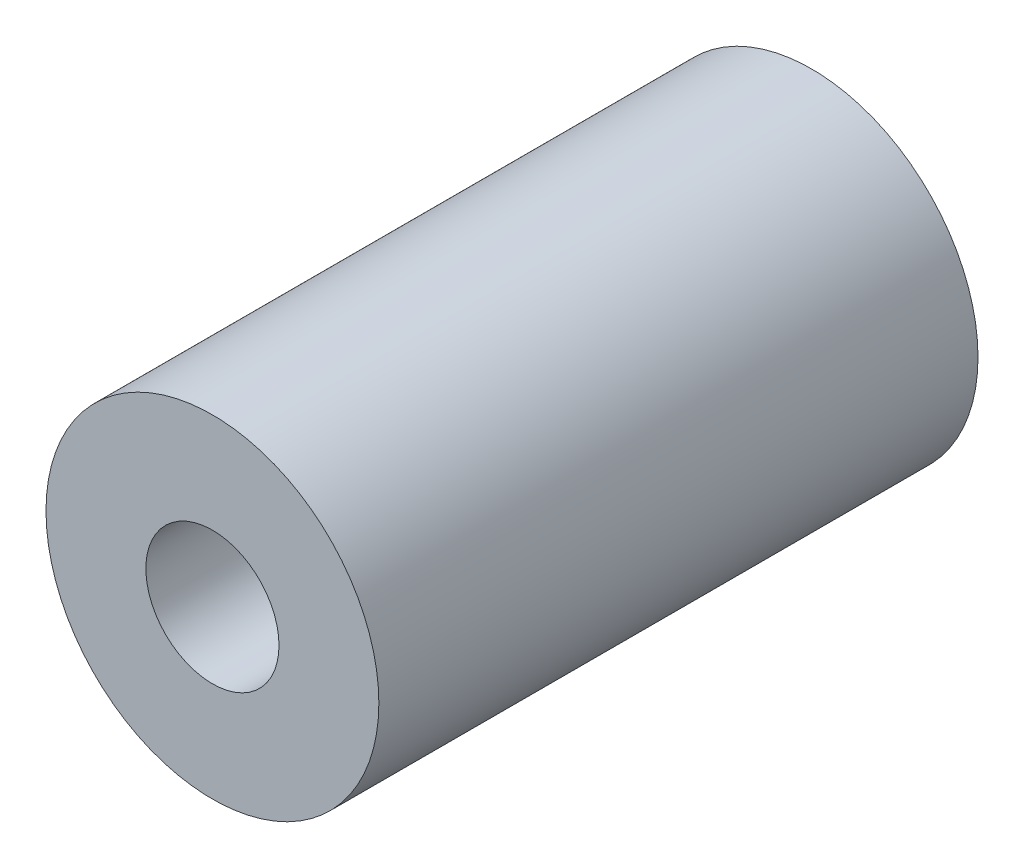
from build123d import *

# Parameters (mm, degrees)
SKETCH1_R           = 15
SKETCH1_R_2         = 6
BOSS_EXTRUDE1_DEPTH = 54


with BuildPart() as part:
    # Sketch1 → Boss-Extrude1 (new body)
    with BuildSketch(Plane.XY):
        Circle(SKETCH1_R)
        Circle(SKETCH1_R_2, mode=Mode.SUBTRACT)
    extrude(amount=BOSS_EXTRUDE1_DEPTH)


solid = part.part
